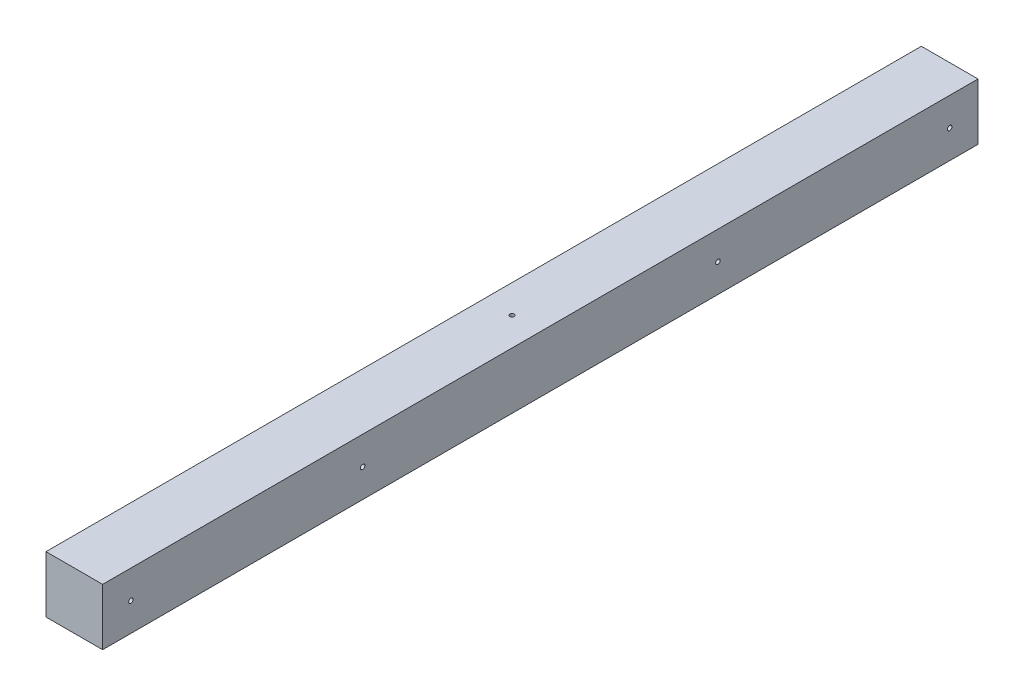
from build123d import *

# Parameters (mm, degrees)
ESQUISSE1_W             = 44
ESQUISSE1_H             = 44
BOSS_EXTRU_1_DEPTH      = 680
ESQUISSE2_R             = 1.75
ENL_V_MAT_EXTRU_1_DEPTH = 44
ESQUISSE3_R             = 1.75
ENL_V_MAT_EXTRU_2_DEPTH = 60


with BuildPart() as part:
    # Esquisse1 → Boss.-Extru.1 (new body)
    with BuildSketch(Plane.XY):
        Rectangle(ESQUISSE1_W, ESQUISSE1_H)
    extrude(amount=BOSS_EXTRU_1_DEPTH)

    # Esquisse2 → Enlèv. mat.-Extru.1 (cut)
    with BuildSketch(Plane(origin=(-22, 0, 0), x_dir=(0, -1, 0), z_dir=(1, 0, 0))):
        with Locations((0, -22)):
            Circle(ESQUISSE2_R)
        with Locations((0, -658)):
            Circle(ESQUISSE2_R)
        with Locations((0, -202)):
            Circle(ESQUISSE2_R)
        with Locations((0, -478)):
            Circle(ESQUISSE2_R)
    extrude(amount=ENL_V_MAT_EXTRU_1_DEPTH, mode=Mode.SUBTRACT)

    # Esquisse3 → Enlèv. mat.-Extru.2 (cut)
    with BuildSketch(Plane.XZ.offset(22)):
        with Locations((0, 340)):
            Circle(ESQUISSE3_R)
    extrude(amount=-ENL_V_MAT_EXTRU_2_DEPTH, mode=Mode.SUBTRACT)


solid = part.part
